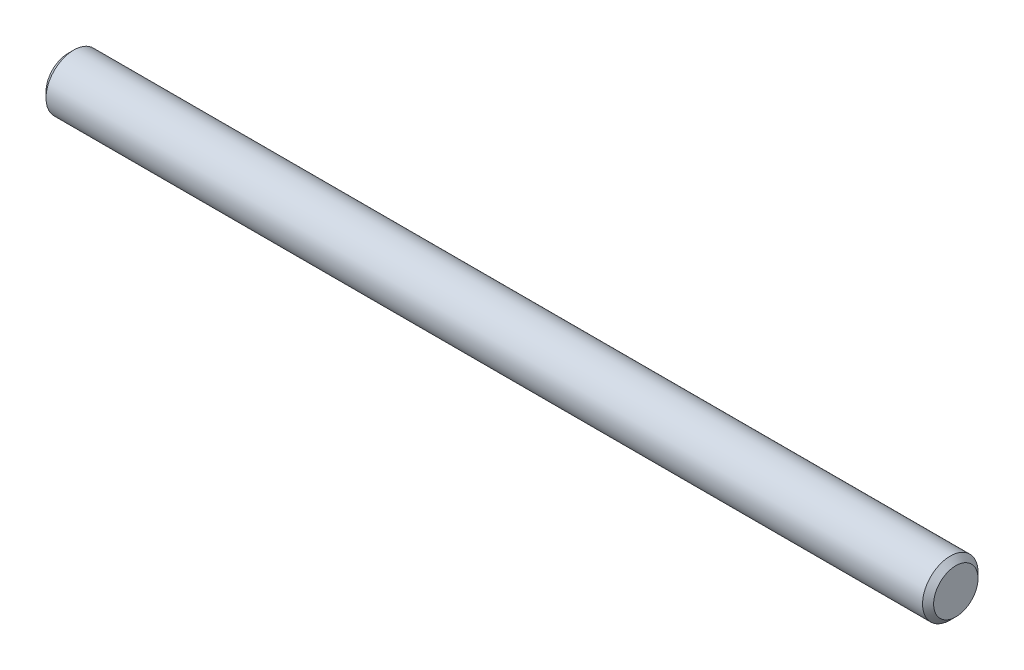
from build123d import *

# Parameters (mm, degrees)
SKETCH2_R           = 1.5875
EXTRUDE1_DEPTH      = 25.4
EXTRUDE1_DEPTH_BACK = 25.4
CHAMFER1_SIZE       = 0.3175


with BuildPart() as part:
    # Sketch2 → Extrude1 (new body, two sides)
    with BuildSketch(Plane(origin=(0, 0, 0), x_dir=(0, 0, -1), z_dir=(1, 0, 0))) as extrude1_sk:
        Circle(SKETCH2_R)
    extrude(amount=EXTRUDE1_DEPTH)
    extrude(extrude1_sk.sketch, amount=-EXTRUDE1_DEPTH_BACK)

    # Chamfer1
    chamfer1_edges = [part.edges().sort_by_distance(p)[0] for p in [
        (-25.4, 0, 1.5875),
        (25.4, 0, 1.5875),
    ]]
    chamfer(chamfer1_edges, length=CHAMFER1_SIZE)


solid = part.part
